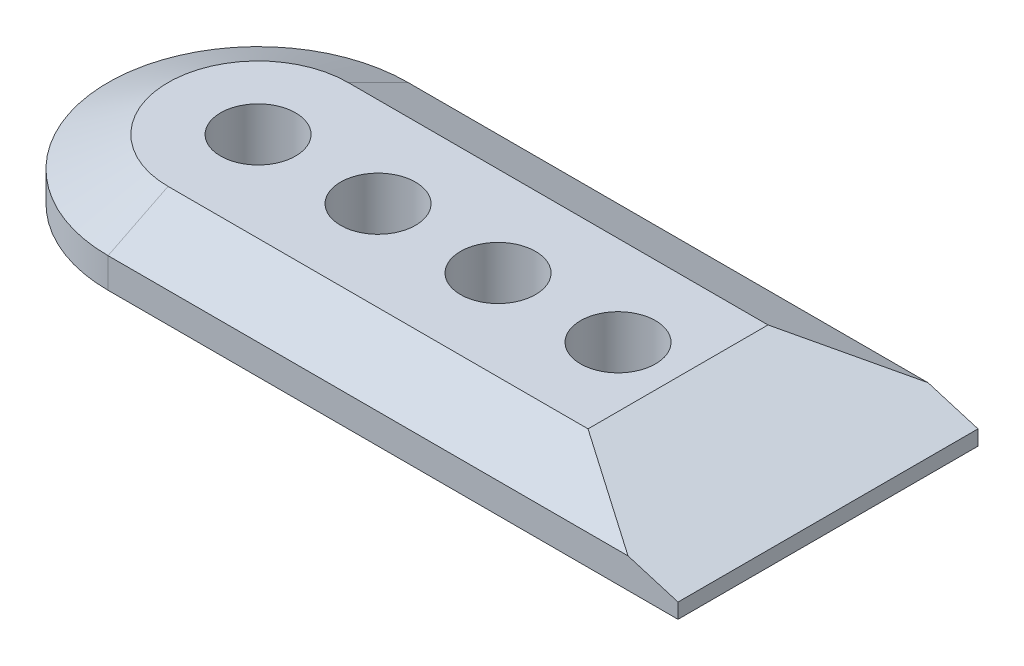
from build123d import *

# Parameters (mm, degrees)
BOSS_EXTRUDE1_DEPTH = 12.7
CHAMFER2_SIZE       = 12.7
CHAMFER2_SIZE2      = 6.35
CHAMFER3_SIZE       = 31.75
CHAMFER3_SIZE2      = 9.525
SKETCH2_R           = 7.9375
CUT_EXTRUDE1_DEPTH  = 13.7


with BuildPart() as part:
    # Sketch1 → Boss-Extrude1 (new body)
    with BuildSketch(Plane(origin=(0, 0, 0), x_dir=(1, 0, 0), z_dir=(0, 1, 0))):
        with BuildLine():
            Line((0, 31.75), (120.65, 31.75))
            Line((120.65, 31.75), (120.65, -31.75))
            Line((120.65, -31.75), (0, -31.75))
            ThreePointArc((0, -31.75), (-31.75, 0), (0, 31.75))
        make_face()
    extrude(amount=BOSS_EXTRUDE1_DEPTH)

    # Chamfer2
    chamfer2_edges = [part.edges().sort_by_distance(p)[0] for p in [
        (60.325, 12.7, 31.75),
        (-31.75, 12.7, 0),
        (60.325, 12.7, -31.75),
    ]]
    chamfer2_side = [part.faces().sort_by_distance(p)[0] for p in [
        (47.684335989, 12.7, 0),
    ]]
    chamfer(chamfer2_edges, length=CHAMFER2_SIZE, length2=CHAMFER2_SIZE2, reference=chamfer2_side[0])

    # Chamfer3
    chamfer3_edges = [part.edges().sort_by_distance(p)[0] for p in [
        (120.65, 12.7, 0),
    ]]
    chamfer3_side = [part.faces().sort_by_distance(p)[0] for p in [
        (52.777427201, 12.7, 0),
    ]]
    chamfer(chamfer3_edges, length=CHAMFER3_SIZE, length2=CHAMFER3_SIZE2, reference=chamfer3_side[0])

    # Sketch2 → Cut-Extrude1 (cut, through all)
    with BuildSketch(Plane(origin=(0, 12.7, 0), x_dir=(1, 0, 0), z_dir=(0, 1, 0))):
        Circle(SKETCH2_R)
        with Locations((25.4, 0)):
            Circle(SKETCH2_R)
        with Locations((50.8, 0)):
            Circle(SKETCH2_R)
        with Locations((76.2, 0)):
            Circle(SKETCH2_R)
    extrude(amount=-CUT_EXTRUDE1_DEPTH, mode=Mode.SUBTRACT)


solid = part.part
